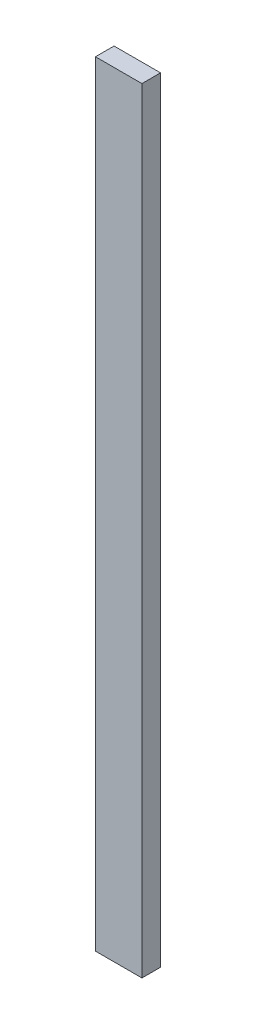
from build123d import *

# Parameters (mm, degrees)
ESQUISSE1_W        = 15
ESQUISSE1_H        = 250
BOSS_EXTRU_1_DEPTH = 6


with BuildPart() as part:
    # Esquisse1 → Boss.-Extru.1 (new body)
    with BuildSketch(Plane.XY):
        Rectangle(ESQUISSE1_W, ESQUISSE1_H)
    extrude(amount=BOSS_EXTRU_1_DEPTH)


solid = part.part
